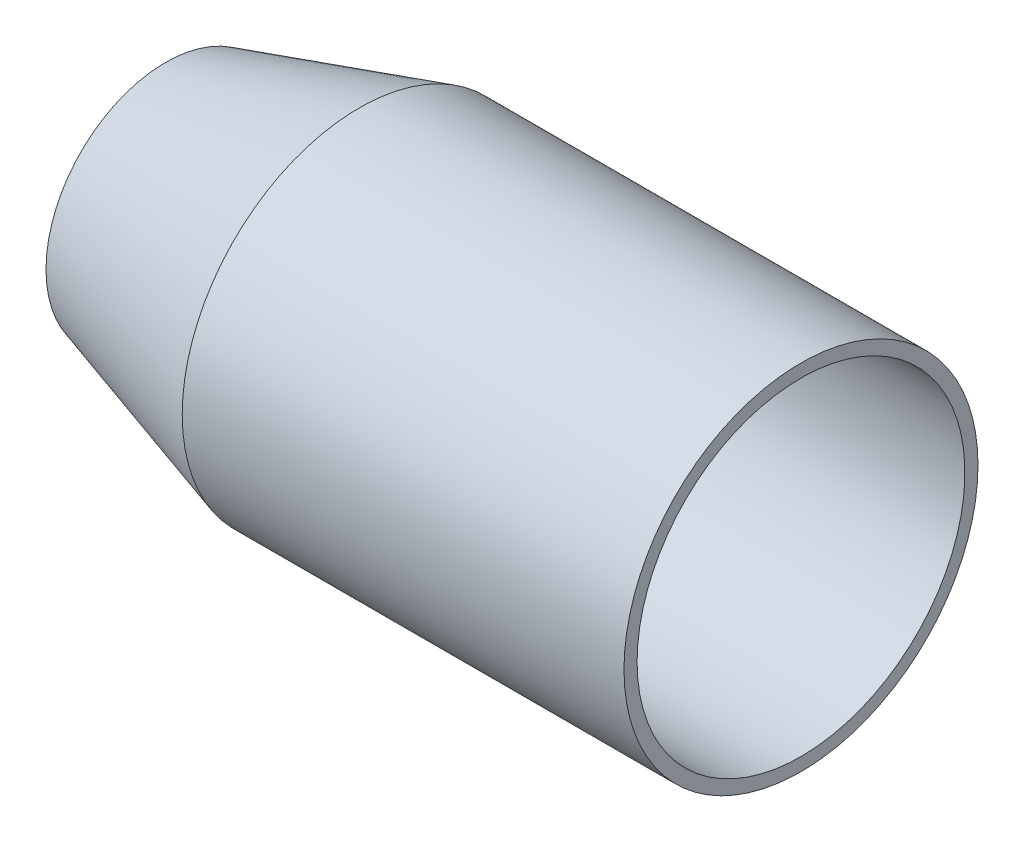
from build123d import *


with BuildPart() as part:
    # Sketch1 → Revolve1 (revolve)
    with BuildSketch(Plane.XY):
        Polygon((239.01, 68.795), (266.7, 68.795), (266.7, 74.295), (239.01, 74.295), (81.28, 74.295), (0, 50.18683312), (0, 44.45), (82.078476138, 68.795), align=None)
    revolve(axis=Axis((0, 0, 0), (1, 0, 0)))


solid = part.part
